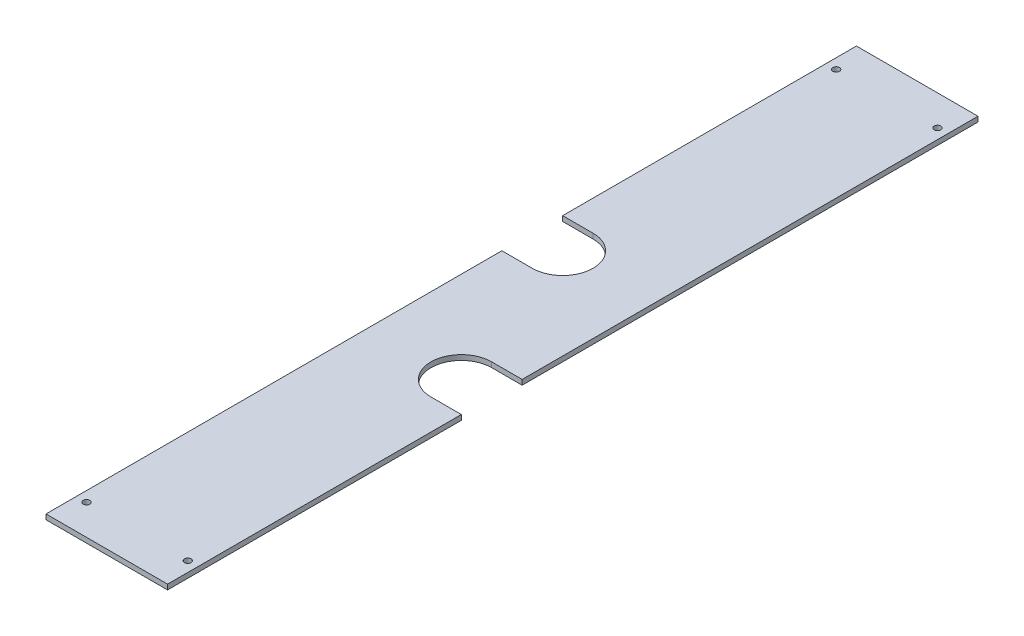
from build123d import *

# Parameters (mm, degrees)
SKETCH1_W           = 76.2
SKETCH1_H           = 3.175
BOSS_EXTRUDE1_DEPTH = 508
CUT_EXTRUDE1_DEPTH  = 4.175
SKETCH4_R           = 2.0828
CUT_EXTRUDE2_DEPTH  = 4.175


with BuildPart() as part:
    # Sketch1 → Boss-Extrude1 (new body)
    with BuildSketch(Plane.XY):
        with Locations((0, 21.307750599)):
            Rectangle(SKETCH1_W, SKETCH1_H)
    extrude(amount=BOSS_EXTRUDE1_DEPTH)

    # Sketch2 → Cut-Extrude1 (cut, through all)
    with BuildSketch(Plane(origin=(0, 22.895250599, 0), x_dir=(1, 0, 0), z_dir=(0, 1, 0))):
        with BuildLine():
            Line((-19.05, -184.15), (-38.1, -184.15))
            Line((-38.1, -184.15), (-38.1, -222.25))
            Line((-38.1, -222.25), (-19.05, -222.25))
            ThreePointArc((-19.05, -222.25), (0, -203.2), (-19.05, -184.15))
        make_face()
        with BuildLine():
            Line((19.05, -323.85), (38.1, -323.85))
            Line((38.1, -323.85), (38.1, -285.75))
            Line((38.1, -285.75), (19.05, -285.75))
            ThreePointArc((19.05, -285.75), (0, -304.8), (19.05, -323.85))
        make_face()
    extrude(amount=-CUT_EXTRUDE1_DEPTH, mode=Mode.SUBTRACT)

    # Sketch4 → Cut-Extrude2 (cut, through all)
    with BuildSketch(Plane(origin=(0, 22.895250599, 0), x_dir=(1, 0, 0), z_dir=(0, 1, 0))):
        with Locations((-31.75, -488.95)):
            Circle(SKETCH4_R)
        with Locations((31.75, -19.05)):
            Circle(SKETCH4_R)
    cut_extrude2 = extrude(amount=-CUT_EXTRUDE2_DEPTH, mode=Mode.SUBTRACT)

    # Mirror2: Cut-Extrude2 across plane
    add(cut_extrude2.mirror(Plane.XY.offset(254)), mode=Mode.SUBTRACT)


solid = part.part
